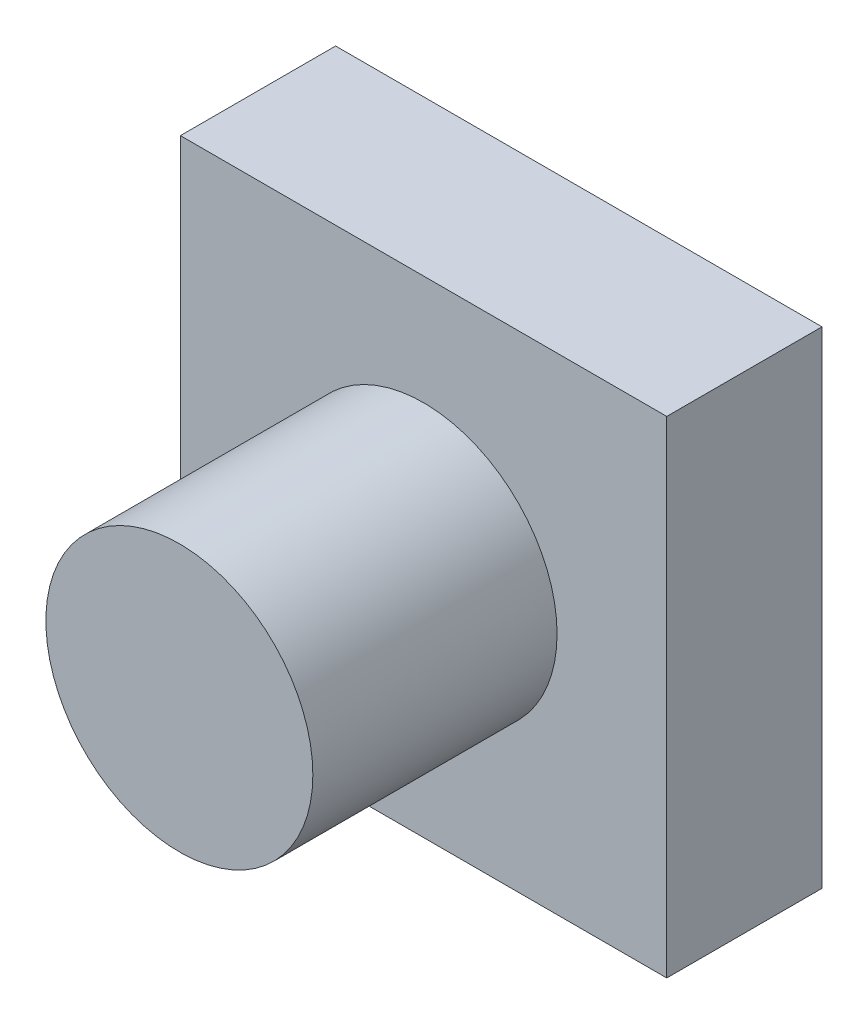
from build123d import *

# Parameters (mm, degrees)
SKETCH1_W           = 11.938
SKETCH1_H           = 11.938
BOSS_EXTRUDE1_DEPTH = 3.81
SKETCH2_R           = 3.2766
BOSS_EXTRUDE2_DEPTH = 5.9944


with BuildPart() as part:
    # Sketch1 → Boss-Extrude1 (new body)
    with BuildSketch(Plane.XY):
        with Locations((5.969, 5.969)):
            Rectangle(SKETCH1_W, SKETCH1_H)
    extrude(amount=BOSS_EXTRUDE1_DEPTH)

    # Sketch2 → Boss-Extrude2 (add)
    with BuildSketch(Plane.XY.offset(3.81)):
        with Locations((5.969, 5.969)):
            Circle(SKETCH2_R)
    extrude(amount=BOSS_EXTRUDE2_DEPTH)


solid = part.part
